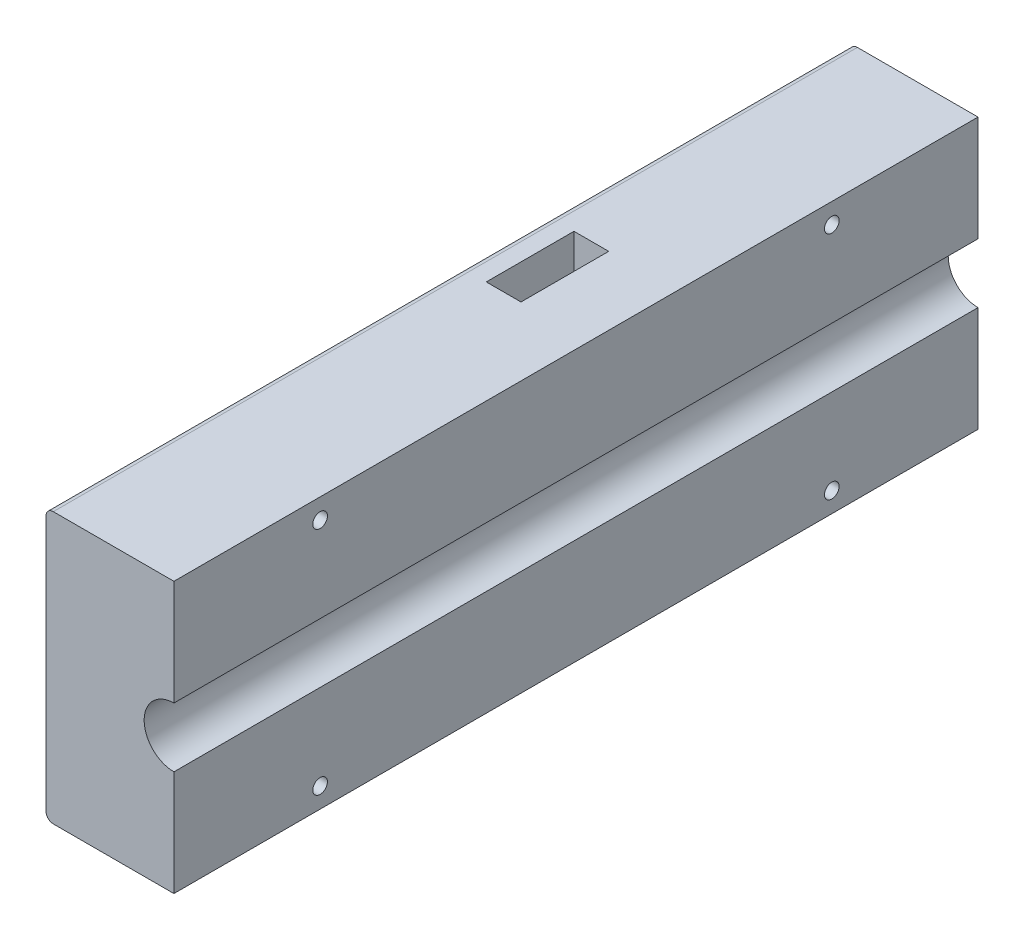
from build123d import *

# Parameters (mm, degrees)
SALIENTE_EXTRUIR1_DEPTH = 220
CORTAR_EXTRUIR2_DEPTH   = 14
CROQUIS2_9_W            = 24
CROQUIS2_9_H            = 1
CROQUIS2_9_W_2          = 5
CORTAR_EXTRUIR3_DEPTH   = 3
CROQUIS4_R              = 1.5
CORTAR_EXTRUIR4_DEPTH   = 10
CROQUIS5_R              = 2
CORTAR_EXTRUIR5_DEPTH   = 36
CROQUIS6_W              = 55
CROQUIS6_H              = 15
CORTAR_EXTRUIR7_DEPTH   = 10
CORTAR_EXTRUIR8_DEPTH   = 30


with BuildPart() as part:
    # Croquis1 → Saliente-Extruir1 (new body)
    with BuildSketch(Plane.XY):
        with BuildLine():
            Line((0, 37), (0, 8.15))
            ThreePointArc((0, 8.15), (-8.15, 0), (0, -8.15))
            Line((0, -8.15), (0, -37))
            Line((0, -37), (-33, -37))
            ThreePointArc((-33, -37), (-34.414213562, -36.414213562), (-35, -35))
            Line((-35, -35), (-35, 35))
            ThreePointArc((-35, 35), (-34.414213562, 36.414213562), (-33, 37))
            Line((-33, 37), (0, 37))
        make_face()
    extrude(amount=SALIENTE_EXTRUIR1_DEPTH)

    # Croquis2 → Cortar-Extruir2 (cut)
    with BuildSketch(Plane.ZY.offset(35)):
        Polygon((50.34, -1.15), (82.34, -1.15), (82.34, -17.5), (156.34, -17.5), (156.34, -1.15), (169.34, -1.15), (169.34, -13.5), (196.34, -13.5), (196.34, 13.5), (169.34, 13.5), (169.34, 1.15), (156.34, 1.15), (156.34, 17.5), (82.34, 17.5), (82.34, 1.15), (50.34, 1.15), (50.34, 10.5), (10, 10.5), (10, -10.5), (50.34, -10.5), align=None)
    extrude(amount=-CORTAR_EXTRUIR2_DEPTH, mode=Mode.SUBTRACT)

    # Croquis2_9 → Cortar-Extruir3 (cut)
    with BuildSketch(Plane.ZY.offset(35)):
        Polygon((54.34, 1.15), (54.34, 2.15), (54.34, 14.5), (6, 14.5), (6, -14.5), (54.34, -14.5), (54.34, -2.15), (54.34, -1.15), (50.34, -1.15), (50.34, -10.5), (10, -10.5), (10, 10.5), (50.34, 10.5), (50.34, 1.15), align=None)
        with Locations((66.34, 1.65)):
            Rectangle(CROQUIS2_9_W, CROQUIS2_9_H)
        with Locations((66.34, -1.65)):
            Rectangle(CROQUIS2_9_W, CROQUIS2_9_H)
        Polygon((78.34, 21.5), (78.34, 2.15), (78.34, 1.15), (82.34, 1.15), (82.34, 17.5), (156.34, 17.5), (156.34, 1.15), (160.34, 1.15), (160.34, 2.15), (160.34, 21.5), align=None)
        Polygon((82.34, -1.15), (78.34, -1.15), (78.34, -2.15), (78.34, -21.5), (160.34, -21.5), (160.34, -2.15), (160.34, -1.15), (156.34, -1.15), (156.34, -17.5), (82.34, -17.5), align=None)
        with Locations((162.84, 1.65)):
            Rectangle(CROQUIS2_9_W_2, CROQUIS2_9_H)
        with Locations((162.84, -1.65)):
            Rectangle(CROQUIS2_9_W_2, CROQUIS2_9_H)
        Polygon((165.34, 17.5), (165.34, 2.15), (165.34, 1.15), (169.34, 1.15), (169.34, 13.5), (196.34, 13.5), (196.34, -13.5), (169.34, -13.5), (169.34, -1.15), (165.34, -1.15), (165.34, -2.15), (165.34, -17.5), (200.34, -17.5), (200.34, 17.5), align=None)
    extrude(amount=-CORTAR_EXTRUIR3_DEPTH, mode=Mode.SUBTRACT)

    # Croquis4 → Cortar-Extruir4 (cut)
    with BuildSketch(Plane.ZY.offset(35)):
        with Locations((8, 12.5)):
            Circle(CROQUIS4_R)
        with Locations((8, -12.5)):
            Circle(CROQUIS4_R)
        with Locations((52.34, 12.5)):
            Circle(CROQUIS4_R)
        with Locations((52.34, -12.5)):
            Circle(CROQUIS4_R)
        with Locations((80.34, 19.5)):
            Circle(CROQUIS4_R)
        with Locations((158.34, 19.5)):
            Circle(CROQUIS4_R)
        with Locations((80.34, -19.5)):
            Circle(CROQUIS4_R)
        with Locations((158.34, -19.5)):
            Circle(CROQUIS4_R)
        with Locations((167.34, 15.5)):
            Circle(CROQUIS4_R)
        with Locations((198.34, 15.5)):
            Circle(CROQUIS4_R)
        with Locations((167.34, -15.5)):
            Circle(CROQUIS4_R)
        with Locations((198.34, -15.5)):
            Circle(CROQUIS4_R)
    extrude(amount=-CORTAR_EXTRUIR4_DEPTH, mode=Mode.SUBTRACT)

    # Croquis5 → Cortar-Extruir5 (cut, through all)
    with BuildSketch(Plane.ZY.offset(35)):
        with Locations((40, 31.5)):
            Circle(CROQUIS5_R)
        with Locations((40, -31.5)):
            Circle(CROQUIS5_R)
        with Locations((180, 31.5)):
            Circle(CROQUIS5_R)
        with Locations((180, -31.5)):
            Circle(CROQUIS5_R)
    extrude(amount=-CORTAR_EXTRUIR5_DEPTH, mode=Mode.SUBTRACT)

    # Croquis6 → Cortar-Extruir7 (cut)
    with BuildSketch(Plane.ZY.offset(21)):
        with Locations((128.84, 10)):
            Rectangle(CROQUIS6_W, CROQUIS6_H)
    extrude(amount=-CORTAR_EXTRUIR7_DEPTH, mode=Mode.SUBTRACT)

    # Croquis12 → Cortar-Extruir8 (cut)
    with BuildSketch(Plane(origin=(0, 37, 0), x_dir=(1, 0, 0), z_dir=(0, 1, 0))):
        Polygon((-19.700712137, -82.34), (-18.7, -82.34), (-18.7, -106.34), (-28.2, -106.34), (-28.2, -82.34), align=None)
    extrude(amount=-CORTAR_EXTRUIR8_DEPTH, mode=Mode.SUBTRACT)


solid = part.part
